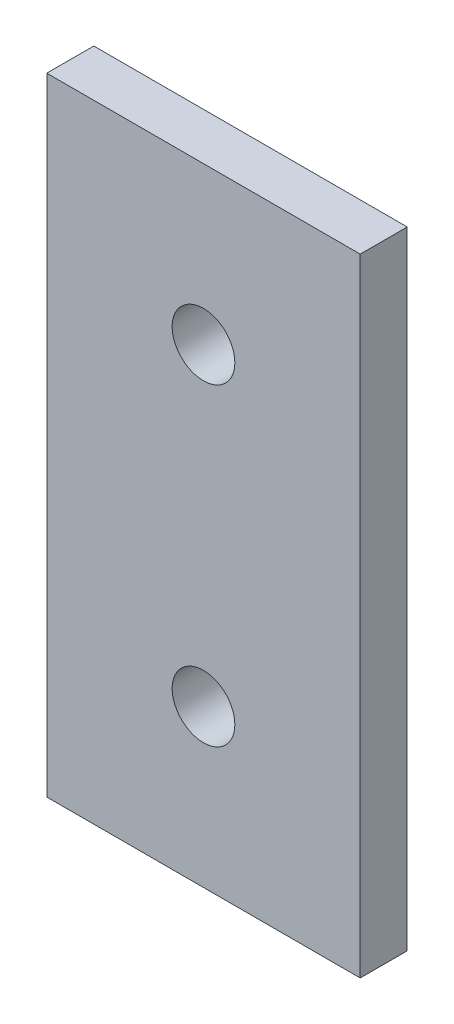
from build123d import *

# Parameters (mm, degrees)
SKETCH1_W           = 20
SKETCH1_H           = 40
BOSS_EXTRUDE1_DEPTH = 3
SKETCH2_R           = 2
CUT_EXTRUDE1_DEPTH  = 4
SKETCH3_R           = 2
CUT_EXTRUDE2_DEPTH  = 4


with BuildPart() as part:
    # Sketch1 → Boss-Extrude1 (new body)
    with BuildSketch(Plane.XY):
        with Locations((10, 20)):
            Rectangle(SKETCH1_W, SKETCH1_H)
    extrude(amount=BOSS_EXTRUDE1_DEPTH)

    # Sketch2 → Cut-Extrude1 (cut, through all)
    with BuildSketch(Plane.XY.offset(3)):
        with Locations((10, 10)):
            Circle(SKETCH2_R)
    extrude(amount=-CUT_EXTRUDE1_DEPTH, mode=Mode.SUBTRACT)

    # Sketch3 → Cut-Extrude2 (cut, through all)
    with BuildSketch(Plane.XY.offset(3)):
        with Locations((10, 30)):
            Circle(SKETCH3_R)
    extrude(amount=-CUT_EXTRUDE2_DEPTH, mode=Mode.SUBTRACT)


solid = part.part
